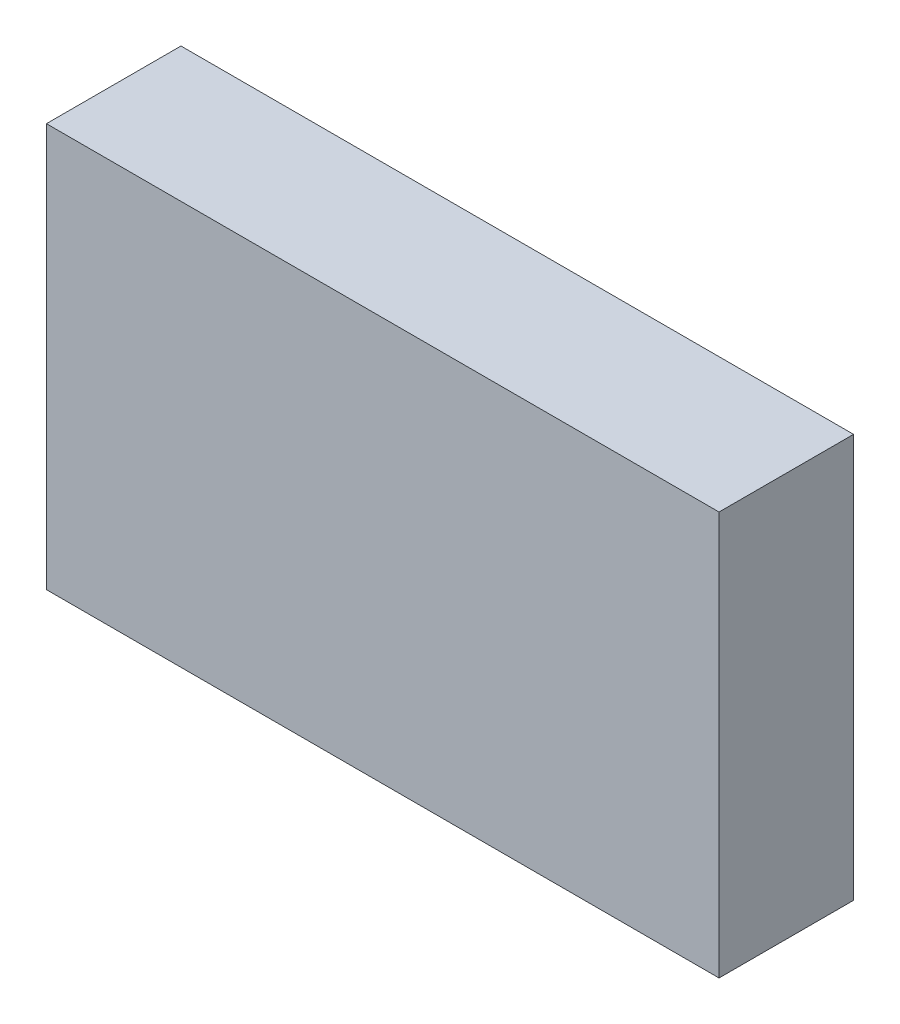
from build123d import *

# Parameters (mm, degrees)
SKETCH1_W       = 10
SKETCH1_H       = 6
MAIN_BODY_DEPTH = 2
SKETCH2_R       = 2.5
SHAFT_CUT_DEPTH = 1


with BuildPart() as part:
    # Sketch1 → main_body (new body)
    with BuildSketch(Plane.XY):
        with Locations((5, 3)):
            Rectangle(SKETCH1_W, SKETCH1_H)
    extrude(amount=MAIN_BODY_DEPTH)

    # Sketch2 → shaft_cut (cut)
    with BuildSketch(Plane(origin=(0, 0, 0), x_dir=(-1, 0, 0), z_dir=(0, 0, -1))):
        with Locations((-5, 3)):
            Circle(SKETCH2_R)
    extrude(amount=-SHAFT_CUT_DEPTH, mode=Mode.SUBTRACT)


solid = part.part
